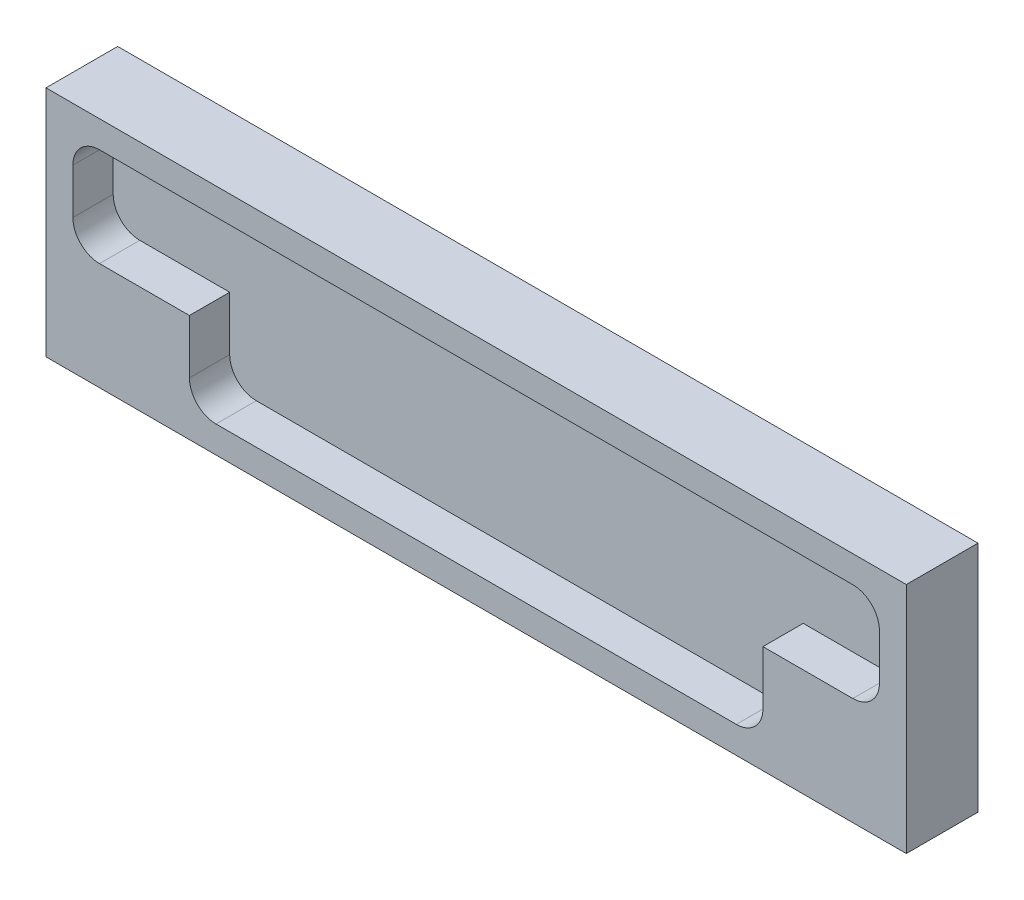
from build123d import *

# Parameters (mm, degrees)
SKETCH1_W           = 152.4
SKETCH1_H           = 41.275
BOSS_EXTRUDE1_DEPTH = 12.7
CUT_EXTRUDE1_DEPTH  = 7.1374


with BuildPart() as part:
    # Sketch1 → Boss-Extrude1 (new body)
    with BuildSketch(Plane.XY):
        Rectangle(SKETCH1_W, SKETCH1_H)
    extrude(amount=BOSS_EXTRUDE1_DEPTH)

    # Sketch2 → Cut-Extrude1 (cut)
    with BuildSketch(Plane.XY.offset(12.7)):
        with BuildLine():
            Line((-66.718427065, 15.875), (66.718427065, 15.875))
            ThreePointArc((66.718427065, 15.875), (70.055315538, 14.492815538), (71.4375, 11.155927065))
            Line((71.4375, 11.155927065), (71.4375, 3.131572935))
            ThreePointArc((71.4375, 3.131572935), (70.055315538, -0.205315538), (66.718427065, -1.5875))
            Line((66.718427065, -1.5875), (50.8, -1.5875))
            Line((50.8, -1.5875), (50.8, -11.155927065))
            ThreePointArc((50.8, -11.155927065), (49.417815538, -14.492815538), (46.080927065, -15.875))
            Line((46.080927065, -15.875), (-46.080927065, -15.875))
            ThreePointArc((-46.080927065, -15.875), (-49.417815538, -14.492815538), (-50.8, -11.155927065))
            Line((-50.8, -11.155927065), (-50.8, -1.5875))
            Line((-50.8, -1.5875), (-66.718427065, -1.5875))
            ThreePointArc((-66.718427065, -1.5875), (-70.055315538, -0.205315538), (-71.4375, 3.131572935))
            Line((-71.4375, 3.131572935), (-71.4375, 11.155927065))
            ThreePointArc((-71.4375, 11.155927065), (-70.055315538, 14.492815538), (-66.718427065, 15.875))
        make_face()
    extrude(amount=-CUT_EXTRUDE1_DEPTH, mode=Mode.SUBTRACT)


solid = part.part
